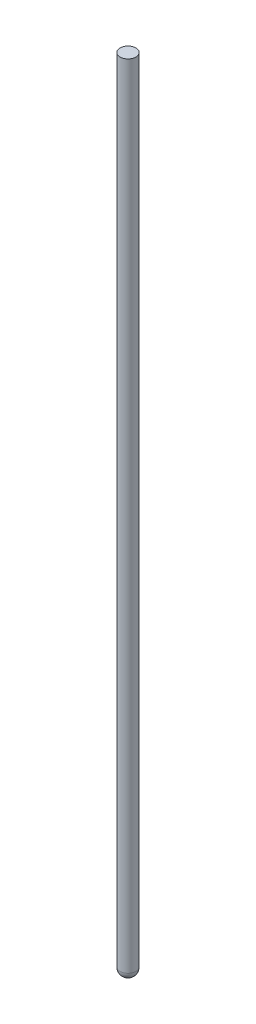
from build123d import *

# Parameters (mm, degrees)
SKETCH1_W         = 0.5
SKETCH1_H         = 50
DOME1_FACE_RADIUS = 0.5
DOME1_HEIGHT      = 0.5


with BuildPart() as part:
    # Sketch1 → Revolve1 (revolve)
    with BuildSketch(Plane.XY):
        with Locations((0.25, 25)):
            Rectangle(SKETCH1_W, SKETCH1_H)
    revolve(axis=Axis((0, 0, 0), (0, -1, 0)))

    # Dome1: a dome of height H over a round flat face of radius A is a cap of a sphere of radius (A * A + H * H) / (2 * H)
    dome1_r = (DOME1_FACE_RADIUS * DOME1_FACE_RADIUS + DOME1_HEIGHT * DOME1_HEIGHT) / (2 * DOME1_HEIGHT)
    dome1_base = Plane((0, 0, 0), z_dir=(0, -1, 0))
    with Locations(dome1_base.offset(DOME1_HEIGHT - dome1_r)):
        dome1_ball = Sphere(dome1_r, mode=Mode.PRIVATE)
    add(split(dome1_ball, bisect_by=dome1_base, keep=Keep.TOP, mode=Mode.PRIVATE))


solid = part.part
